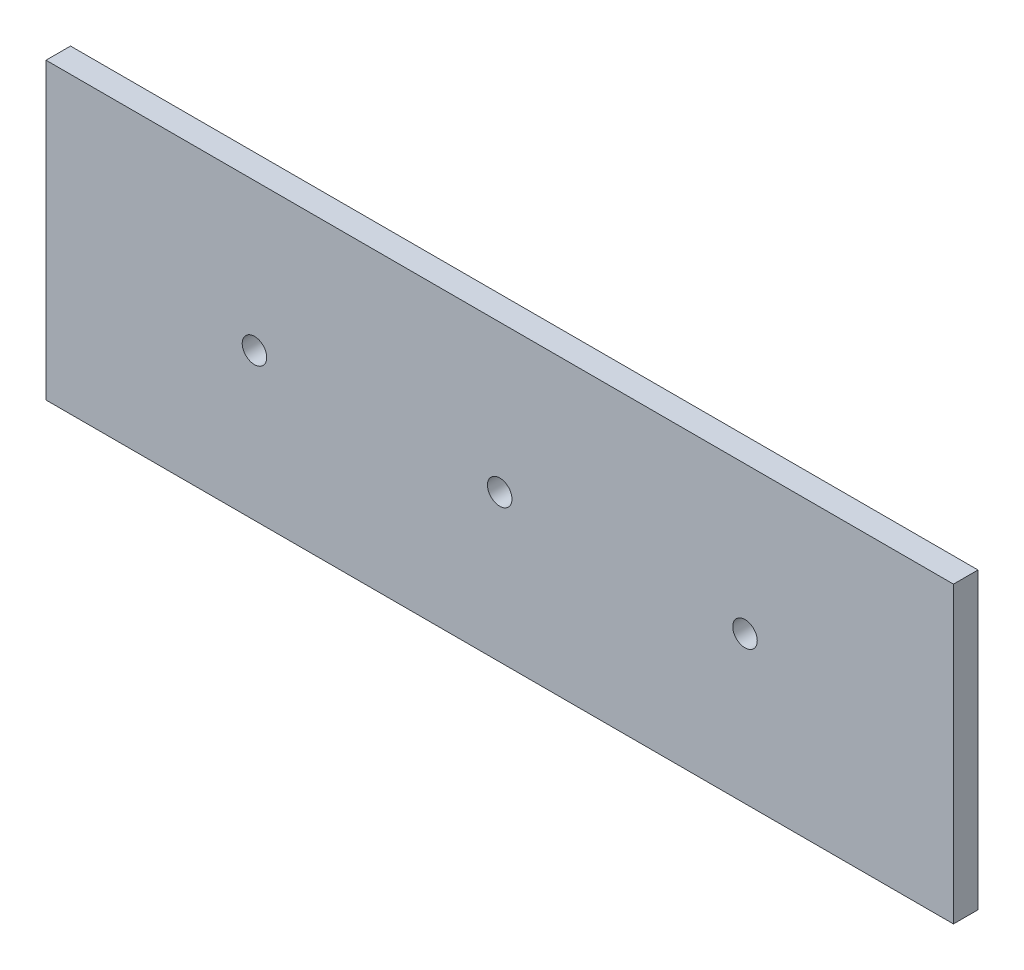
from build123d import *

# Parameters (mm, degrees)
CROQUIS1_W              = 234.95
CROQUIS1_H              = 76.2
SALIENTE_EXTRUIR1_DEPTH = 6.35
CROQUIS2_R              = 3.175
CORTAR_EXTRUIR1_DEPTH   = 7.35


with BuildPart() as part:
    # Croquis1 → Saliente-Extruir1 (new body)
    with BuildSketch(Plane.XY):
        Rectangle(CROQUIS1_W, CROQUIS1_H)
    extrude(amount=SALIENTE_EXTRUIR1_DEPTH)

    # Croquis2 → Cortar-Extruir1 (cut, through all)
    with BuildSketch(Plane.XY.offset(6.35)):
        with BuildLine():
            ThreePointArc((3.175, 0), (2.24506403, 2.24506403), (0, 3.175))
            Line((0, 3.175), (0, -3.175))
            ThreePointArc((0, -3.175), (2.24506403, -2.24506403), (3.175, 0))
        make_face()
        with BuildLine():
            Line((0, -3.175), (0, 3.175))
            ThreePointArc((0, 3.175), (-3.175, 0), (0, -3.175))
        make_face()
        with Locations((-63.5, 0)):
            Circle(CROQUIS2_R)
        with Locations((63.5, 0)):
            Circle(CROQUIS2_R)
    extrude(amount=-CORTAR_EXTRUIR1_DEPTH, mode=Mode.SUBTRACT)


solid = part.part
